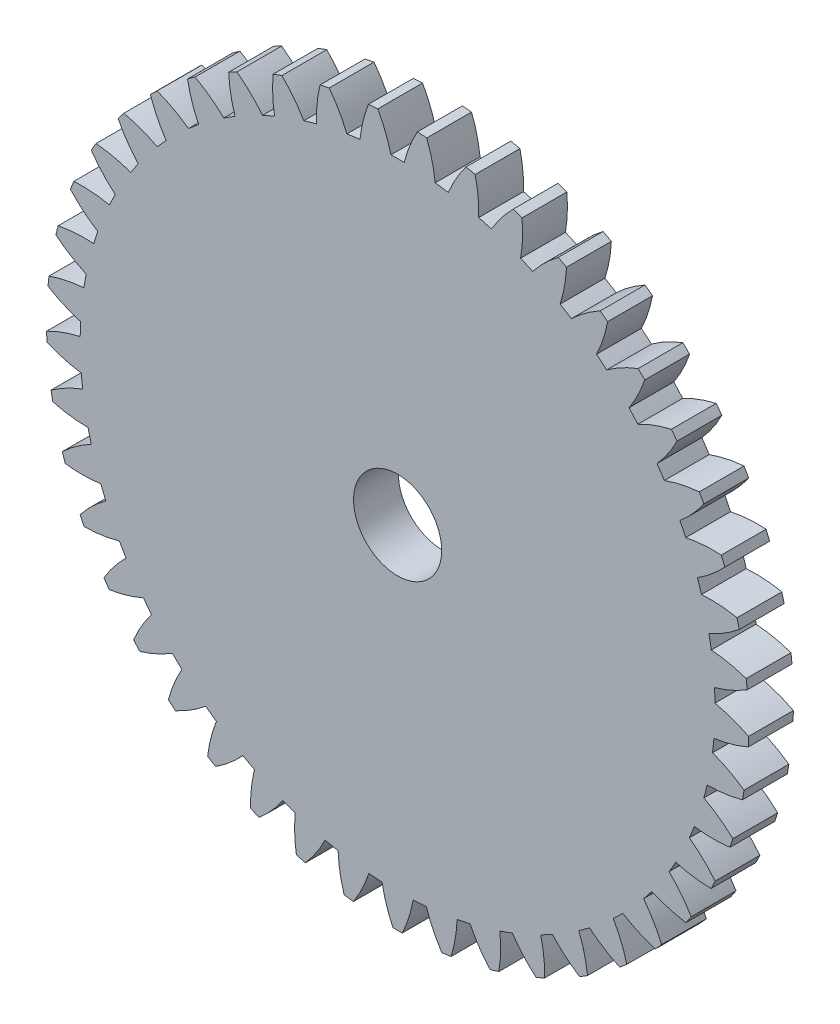
from build123d import *

# Parameters (mm, degrees)
BOSS_EXTRUDE1_DEPTH = 3
SKETCH2_R           = 2.95
CUT_EXTRUDE1_DEPTH  = 3


with BuildPart() as part:
    # Model → Boss-Extrude1 (new body)
    with BuildSketch(Plane.XY):
        with BuildLine():
            ThreePointArc((32.442634493, 93.418604181), (32.407825649, 93.107382285), (32.377167165, 92.795724168))
            ThreePointArc((32.377167165, 92.795724168), (33.438114337, 92.242398237), (34.563087863, 91.834705887))
            ThreePointArc((34.563087863, 91.834705887), (34.543034507, 91.392542803), (34.532195277, 90.950057955))
            ThreePointArc((34.532195277, 90.950057955), (33.381522949, 90.62183291), (32.284562125, 90.143862787))
            ThreePointArc((32.284562125, 90.143862787), (32.293405755, 89.830825225), (32.306420064, 89.517933307))
            ThreePointArc((32.306420064, 89.517933307), (33.434050257, 89.117647614), (34.604815427, 88.870488953))
            ThreePointArc((34.604815427, 88.870488953), (34.646494435, 88.429838082), (34.697342681, 87.990150937))
            ThreePointArc((34.697342681, 87.990150937), (33.603548714, 87.504977519), (32.583784022, 86.878991529))
            ThreePointArc((32.583784022, 86.878991529), (32.636107994, 86.570231223), (32.692541788, 86.262195589))
            ThreePointArc((32.692541788, 86.262195589), (33.864906962, 86.02274124), (35.058676163, 85.940926928))
            ThreePointArc((35.058676163, 85.940926928), (35.161276302, 85.510365038), (35.272822319, 85.082033606))
            ThreePointArc((35.272822319, 85.082033606), (34.25719617, 84.449355164), (33.334476169, 83.687537413))
            ThreePointArc((33.334476169, 83.687537413), (33.429262057, 83.38906403), (33.528016915, 83.091880244))
            ThreePointArc((33.528016915, 83.091880244), (34.722298316, 83.017917945), (35.915836189, 83.103040406))
            ThreePointArc((35.915836189, 83.103040406), (36.077360464, 82.690947894), (36.247433137, 82.282309159))
            ThreePointArc((36.247433137, 82.282309159), (35.329742812, 81.51444006), (34.522027198, 80.631618462))
            ThreePointArc((34.522027198, 80.631618462), (34.657430102, 80.349241448), (34.796583874, 80.068693855))
            ThreePointArc((34.796583874, 80.068693855), (35.989536173, 80.161663197), (37.15961186, 80.412065619))
            ThreePointArc((37.15961186, 80.412065619), (37.376916385, 80.026463398), (37.602205442, 79.645471048))
            ThreePointArc((37.602205442, 79.645471048), (36.80031274, 78.75735699), (36.123322778, 77.770714665))
            ThreePointArc((36.123322778, 77.770714665), (36.296707235, 77.509930166), (36.47355145, 77.251479304))
            ThreePointArc((36.47355145, 77.251479304), (37.641955188, 77.509570746), (38.765794498, 77.920379331))
            ThreePointArc((38.765794498, 77.920379331), (39.034649687, 77.568772709), (39.310770133, 77.222842327))
            ThreePointArc((39.310770133, 77.222842327), (38.640282982, 76.23176944), (38.107195512, 75.160510257))
            ThreePointArc((38.107195512, 75.160510257), (38.315186791, 74.926394149), (38.526279379, 74.69507047))
            ThreePointArc((38.526279379, 74.69507047), (39.647392905, 75.113260556), (40.703121583, 75.676479381))
            ThreePointArc((40.703121583, 75.676479381), (41.018294476, 75.365711981), (41.339871941, 75.061576708))
            ThreePointArc((41.339871941, 75.061576708), (40.813840613, 73.986835098), (40.435031575, 72.851809901))
            ThreePointArc((40.435031575, 72.851809901), (40.673581362, 72.648918985), (40.914813645, 72.449224943))
            ThreePointArc((40.914813645, 72.449224943), (41.966815761, 73.019374077), (42.933885249, 73.724040729))
            ThreePointArc((42.933885249, 73.724040729), (43.289241364, 73.460161285), (43.650016708, 73.203740769))
            ThreePointArc((43.650016708, 73.203740769), (43.278679803, 72.066249059), (43.061522286, 70.88954982))
            ThreePointArc((43.061522286, 70.88954982), (43.325987481, 70.721833138), (43.592664146, 70.55765555))
            ThreePointArc((43.592664146, 70.55765555), (44.555078827, 71.268666429), (45.414666218, 72.101065373))
            ThreePointArc((45.414666218, 72.101065373), (45.803288952, 71.889209997), (46.196240094, 71.685495172))
            ThreePointArc((46.196240094, 71.685495172), (45.986825263, 70.507393345), (45.935545989, 69.311923177))
            ThreePointArc((45.935545989, 69.311923177), (46.220779078, 69.182645144), (46.507709569, 69.057179539))
            ThreePointArc((46.507709569, 69.057179539), (47.361804507, 69.895213144), (48.09717891, 70.839142682))
            ThreePointArc((48.09717891, 70.839142682), (48.511504164, 70.683434899), (48.928982756, 70.536390841))
            ThreePointArc((48.928982756, 70.536390841), (48.88556602, 69.340609308), (49.001163084, 68.149636678))
            ThreePointArc((49.001163084, 68.149636678), (49.301612328, 68.061313543), (49.603211868, 67.977001967))
            ThreePointArc((49.603211868, 67.977001967), (50.332363078, 68.925746928), (50.929211268, 69.962834545))
            ThreePointArc((50.929211268, 69.962834545), (51.361174672, 69.86630503), (51.795054968, 69.778793785))
            ThreePointArc((51.795054968, 69.778793785), (51.918481385, 68.588607074), (52.19870482, 67.42531291))
            ThreePointArc((52.19870482, 67.42531291), (52.508522317, 67.379663782), (52.818920615, 67.338147264))
            ThreePointArc((52.818920615, 67.338147264), (53.408935997, 68.379137339), (53.855641001, 69.489197304))
            ThreePointArc((53.855641001, 69.489197304), (54.296834879, 69.453724894), (54.738671894, 69.427449769))
            ThreePointArc((54.738671894, 69.427449769), (55.026539108, 68.26602351), (55.465934684, 67.153050009))
            ThreePointArc((55.465934684, 67.153050009), (55.77909019, 67.150963398), (56.092245695, 67.153050009))
            ThreePointArc((56.092245695, 67.153050009), (56.531641271, 68.26602351), (56.819508486, 69.427449769))
            ThreePointArc((56.819508486, 69.427449769), (57.2613455, 69.453724894), (57.702539378, 69.489197304))
            ThreePointArc((57.702539378, 69.489197304), (58.149244383, 68.379137339), (58.739259765, 67.338147264))
            ThreePointArc((58.739259765, 67.338147264), (59.049658062, 67.379663782), (59.35947556, 67.42531291))
            ThreePointArc((59.35947556, 67.42531291), (59.639698995, 68.588607074), (59.763125412, 69.778793785))
            ThreePointArc((59.763125412, 69.778793785), (60.197005708, 69.86630503), (60.628969112, 69.962834545))
            ThreePointArc((60.628969112, 69.962834545), (61.225817302, 68.925746928), (61.954968511, 67.977001967))
            ThreePointArc((61.954968511, 67.977001967), (62.256568052, 68.061313543), (62.557017296, 68.149636678))
            ThreePointArc((62.557017296, 68.149636678), (62.672614359, 69.340609308), (62.629197623, 70.536390841))
            ThreePointArc((62.629197623, 70.536390841), (63.046676215, 70.683434899), (63.461001469, 70.839142682))
            ThreePointArc((63.461001469, 70.839142682), (64.196375873, 69.895213143), (65.050470811, 69.057179538))
            ThreePointArc((65.050470811, 69.057179538), (65.337401302, 69.182645143), (65.622634391, 69.311923176))
            ThreePointArc((65.622634391, 69.311923176), (65.571355117, 70.507393345), (65.361940286, 71.685495172))
            ThreePointArc((65.361940286, 71.685495172), (65.754891427, 71.889209997), (66.143514162, 72.101065373))
            ThreePointArc((66.143514162, 72.101065373), (67.003101553, 71.268666428), (67.965516234, 70.55765555))
            ThreePointArc((67.965516234, 70.55765555), (68.232192899, 70.721833138), (68.496658094, 70.88954982))
            ThreePointArc((68.496658094, 70.88954982), (68.279500577, 72.066249059), (67.908163672, 73.203740769))
            ThreePointArc((67.908163672, 73.203740769), (68.268939016, 73.460161284), (68.624295131, 73.724040729))
            ThreePointArc((68.624295131, 73.724040729), (69.591364619, 73.019374077), (70.643366735, 72.449224943))
            ThreePointArc((70.643366735, 72.449224943), (70.884599017, 72.648918985), (71.123148805, 72.8518099))
            ThreePointArc((71.123148805, 72.8518099), (70.744339767, 73.986835098), (70.218308439, 75.061576708))
            ThreePointArc((70.218308439, 75.061576708), (70.539885904, 75.36571198), (70.855058797, 75.676479381))
            ThreePointArc((70.855058797, 75.676479381), (71.910787474, 75.113260555), (73.031901001, 74.69507047))
            ThreePointArc((73.031901001, 74.69507047), (73.242993589, 74.926394148), (73.450984868, 75.160510257))
            ThreePointArc((73.450984868, 75.160510257), (72.917897397, 76.23176944), (72.247410247, 77.222842327))
            ThreePointArc((72.247410247, 77.222842327), (72.523530693, 77.568772709), (72.792385882, 77.920379331))
            ThreePointArc((72.792385882, 77.920379331), (73.916225192, 77.509570746), (75.084628929, 77.251479304))
            ThreePointArc((75.084628929, 77.251479304), (75.261473145, 77.509930166), (75.434857602, 77.770714665))
            ThreePointArc((75.434857602, 77.770714665), (74.75786764, 78.75735699), (73.955974938, 79.645471048))
            ThreePointArc((73.955974938, 79.645471048), (74.181263995, 80.026463398), (74.39856852, 80.412065619))
            ThreePointArc((74.39856852, 80.412065619), (75.568644207, 80.161663197), (76.761596506, 80.068693855))
            ThreePointArc((76.761596506, 80.068693855), (76.900750278, 80.349241448), (77.036153182, 80.631618462))
            ThreePointArc((77.036153182, 80.631618462), (76.228437568, 81.51444006), (75.310747243, 82.282309159))
            ThreePointArc((75.310747243, 82.282309159), (75.480819916, 82.690947894), (75.642344191, 83.103040406))
            ThreePointArc((75.642344191, 83.103040406), (76.835882063, 83.017917945), (78.030163465, 83.091880244))
            ThreePointArc((78.030163465, 83.091880244), (78.128918323, 83.38906403), (78.223704211, 83.687537413))
            ThreePointArc((78.223704211, 83.687537413), (77.30098421, 84.449355164), (76.28535806, 85.082033606))
            ThreePointArc((76.28535806, 85.082033606), (76.396904077, 85.510365038), (76.499504217, 85.940926928))
            ThreePointArc((76.499504217, 85.940926928), (77.693273418, 86.02274124), (78.865638592, 86.262195589))
            ThreePointArc((78.865638592, 86.262195589), (78.922072386, 86.570231223), (78.974396358, 86.878991529))
            ThreePointArc((78.974396358, 86.878991529), (77.954631666, 87.504977519), (76.860837699, 87.990150937))
            ThreePointArc((76.860837699, 87.990150937), (76.911685945, 88.429838082), (76.953364953, 88.870488953))
            ThreePointArc((76.953364953, 88.870488953), (78.124130123, 89.117647614), (79.251760315, 89.517933307))
            ThreePointArc((79.251760315, 89.517933307), (79.264774625, 89.830825225), (79.273618254, 90.143862787))
            ThreePointArc((79.273618254, 90.143862787), (78.176657431, 90.62183291), (77.025985103, 90.950057955))
            ThreePointArc((77.025985103, 90.950057955), (77.015145873, 91.392542803), (76.995092516, 91.834705887))
            ThreePointArc((76.995092516, 91.834705887), (78.120066043, 92.242398237), (79.181013214, 92.795724168))
            ThreePointArc((79.181013214, 92.795724168), (79.150354731, 93.107382285), (79.115545887, 93.418604181))
            ThreePointArc((79.115545887, 93.418604181), (77.962740026, 93.739255293), (76.777585865, 93.904143438))
            ThreePointArc((76.777585865, 93.904143438), (76.705270134, 94.340813525), (76.623874727, 94.77588262))
            ThreePointArc((76.623874727, 94.77588262), (77.68116028, 95.33617339), (78.654774301, 96.031769699))
            ThreePointArc((78.654774301, 96.031769699), (78.581039757, 96.336127944), (78.503255954, 96.639476596))
            ThreePointArc((78.503255954, 96.639476596), (77.317043112, 96.796567587), (76.120474794, 96.794909472))
            ThreePointArc((76.120474794, 96.794909472), (75.988090105, 97.217265511), (75.846936918, 97.636772493))
            ThreePointArc((75.846936918, 97.636772493), (76.815955636, 98.33875626), (77.683286217, 99.163083956))
            ThreePointArc((77.683286217, 99.163083956), (77.567910772, 99.454218343), (77.448665983, 99.743789414))
            ThreePointArc((77.448665983, 99.743789414), (76.252134442, 99.734262685), (75.06744181, 99.566090585))
            ThreePointArc((75.06744181, 99.566090585), (74.87756488, 99.965911896), (74.679401298, 100.361691538))
            ThreePointArc((74.679401298, 100.361691538), (75.541292335, 101.191704987), (76.285457873, 102.128719469))
            ThreePointArc((76.285457873, 102.128719469), (76.130687179, 102.400963398), (75.972302368, 102.671120715))
            ThreePointArc((75.972302368, 102.671120715), (74.788741254, 102.495161696), (73.638983002, 102.163748887))
            ThreePointArc((73.638983002, 102.163748887), (73.395309569, 102.533253404), (73.143992622, 102.897602305))
            ThreePointArc((73.143992622, 102.897602305), (73.881980249, 103.839490169), (74.488496408, 104.870953516))
            ThreePointArc((74.488496408, 104.870953516), (74.2973429, 105.119008068), (74.102900847, 105.364493328))
            ThreePointArc((74.102900847, 105.364493328), (72.955346831, 105.025526859), (71.862901696, 104.537323916))
            ThreePointArc((71.862901696, 104.537323916), (71.570174586, 104.869319652), (71.270595872, 105.195146176))
            ThreePointArc((71.270595872, 105.195146176), (71.870316, 106.230575679), (72.327377633, 107.33641163))
            ThreePointArc((72.327377633, 107.33641163), (72.103561896, 107.555448706), (71.876847195, 107.771483817))
            ThreePointArc((71.876847195, 107.771483817), (70.78763611, 107.276107495), (69.773767294, 106.640616732))
            ThreePointArc((69.773767294, 106.640616732), (69.437684108, 106.92864177), (69.095674586, 107.209604074))
            ThreePointArc((69.095674586, 107.209604074), (69.545454343, 108.318421758), (69.844165265, 109.477106474))
            ThreePointArc((69.844165265, 109.477106474), (69.592043619, 109.662862766), (69.337469014, 109.84524285))
            ThreePointArc((69.337469014, 109.84524285), (68.327801115, 109.203098612), (67.41224242, 108.432689135))
            ThreePointArc((67.41224242, 108.432689135), (67.039344636, 108.671137393), (66.661561131, 108.901766865))
            ThreePointArc((66.661561131, 108.901766865), (66.952646068, 110.062390856), (67.087192211, 111.251371857))
            ThreePointArc((67.087192211, 111.251371857), (66.811671915, 111.40023183), (66.534192411, 111.545407066))
            ThreePointArc((66.534192411, 111.545407066), (65.623719736, 110.76899352), (64.824291471, 109.878660472))
            ThreePointArc((64.824291471, 109.878660472), (64.421837119, 110.062890827), (64.015632758, 110.238698528))
            ThreePointArc((64.015632758, 110.238698528), (64.142357237, 111.428538598), (64.110119813, 112.624673722))
            ThreePointArc((64.110119813, 112.624673722), (63.816563558, 112.733739986), (63.521579977, 112.838884704))
            ThreePointArc((63.521579977, 112.838884704), (62.72802384, 111.943313856), (62.060285968, 110.950386557))
            ThreePointArc((62.060285968, 110.950386557), (61.636108364, 111.076813175), (61.209389454, 111.194377206))
            ThreePointArc((61.209389454, 111.194377206), (61.169286926, 112.390274474), (60.9708934, 113.570282311))
            ThreePointArc((60.9708934, 113.570282311), (60.665014924, 113.637432015), (60.358268787, 113.700499692))
            ThreePointArc((60.358268787, 113.700499692), (59.697074856, 112.703202809), (59.174024134, 111.62700746))
            ThreePointArc((59.174024134, 111.62700746), (58.736379412, 111.693169591), (58.29745155, 111.750201703))
            ThreePointArc((58.29745155, 111.750201703), (58.091302566, 112.928879387), (57.730614443, 114.069792427))
            ThreePointArc((57.730614443, 114.069792427), (57.418367323, 114.093718579), (57.105829094, 114.113481675))
            ThreePointArc((57.105829094, 114.113481675), (56.589866756, 113.033870007), (56.221683772, 111.895353526))
            ThreePointArc((56.221683772, 111.895353526), (55.77909019, 111.899963398), (55.336496608, 111.895353526))
            ThreePointArc((55.336496608, 111.895353526), (54.968313623, 113.033870007), (54.452351286, 114.113481674))
            ThreePointArc((54.452351286, 114.113481674), (54.139813057, 114.093718579), (53.827565937, 114.069792427))
            ThreePointArc((53.827565937, 114.069792427), (53.466877813, 112.928879387), (53.260728829, 111.750201703))
            ThreePointArc((53.260728829, 111.750201703), (52.821800968, 111.693169591), (52.384156246, 111.62700746))
            ThreePointArc((52.384156246, 111.62700746), (51.861105524, 112.703202809), (51.199911593, 113.700499692))
            ThreePointArc((51.199911593, 113.700499692), (50.893165456, 113.637432015), (50.58728698, 113.570282311))
            ThreePointArc((50.58728698, 113.570282311), (50.388893454, 112.390274474), (50.348790926, 111.194377206))
            ThreePointArc((50.348790926, 111.194377206), (49.922072016, 111.076813175), (49.497894412, 110.950386557))
            ThreePointArc((49.497894412, 110.950386557), (48.830156539, 111.943313856), (48.036600402, 112.838884704))
            ThreePointArc((48.036600402, 112.838884704), (47.741616822, 112.733739986), (47.448060567, 112.624673722))
            ThreePointArc((47.448060567, 112.624673722), (47.415823143, 111.428538598), (47.542547621, 110.238698528))
            ThreePointArc((47.542547621, 110.238698528), (47.136343261, 110.062890827), (46.733888908, 109.878660472))
            ThreePointArc((46.733888908, 109.878660472), (45.934460644, 110.76899352), (45.023987969, 111.545407066))
            ThreePointArc((45.023987969, 111.545407066), (44.746508464, 111.40023183), (44.470988169, 111.251371857))
            ThreePointArc((44.470988169, 111.251371857), (44.605534312, 110.062390856), (44.896619248, 108.901766866))
            ThreePointArc((44.896619248, 108.901766866), (44.518835744, 108.671137393), (44.145937959, 108.432689135))
            ThreePointArc((44.145937959, 108.432689135), (43.230379264, 109.203098612), (42.220711366, 109.84524285))
            ThreePointArc((42.220711366, 109.84524285), (41.966136761, 109.662862766), (41.714015114, 109.477106474))
            ThreePointArc((41.714015114, 109.477106474), (42.012726036, 108.318421758), (42.462505794, 107.209604074))
            ThreePointArc((42.462505794, 107.209604074), (42.120496272, 106.92864177), (41.784413086, 106.640616733))
            ThreePointArc((41.784413086, 106.640616733), (40.770544269, 107.276107495), (39.681333185, 107.771483817))
            ThreePointArc((39.681333185, 107.771483817), (39.454618484, 107.555448706), (39.230802747, 107.33641163))
            ThreePointArc((39.230802747, 107.33641163), (39.68786438, 106.230575679), (40.287584507, 105.195146176))
            ThreePointArc((40.287584507, 105.195146176), (39.988005793, 104.869319652), (39.695278684, 104.537323916))
            ThreePointArc((39.695278684, 104.537323916), (38.602833549, 105.025526859), (37.455279533, 105.364493328))
            ThreePointArc((37.455279533, 105.364493328), (37.26083748, 105.119008068), (37.069683971, 104.870953516))
            ThreePointArc((37.069683971, 104.870953516), (37.67620013, 103.839490169), (38.414187758, 102.897602305))
            ThreePointArc((38.414187758, 102.897602305), (38.162870811, 102.533253404), (37.919197377, 102.163748887))
            ThreePointArc((37.919197377, 102.163748887), (36.769439126, 102.495161696), (35.585878012, 102.671120715))
            ThreePointArc((35.585878012, 102.671120715), (35.427493201, 102.400963398), (35.272722506, 102.128719469))
            ThreePointArc((35.272722506, 102.128719469), (36.016888044, 101.191704987), (36.878779081, 100.361691538))
            ThreePointArc((36.878779081, 100.361691538), (36.6806155, 99.965911896), (36.490738569, 99.566090585))
            ThreePointArc((36.490738569, 99.566090585), (35.306045938, 99.734262686), (34.109514397, 99.743789414))
            ThreePointArc((34.109514397, 99.743789414), (33.990269607, 99.454218343), (33.874894162, 99.163083956))
            ThreePointArc((33.874894162, 99.163083956), (34.742224744, 98.33875626), (35.711243462, 97.636772493))
            ThreePointArc((35.711243462, 97.636772493), (35.570090275, 97.217265511), (35.437705585, 96.794909472))
            ThreePointArc((35.437705585, 96.794909472), (34.241137268, 96.796567587), (33.054924426, 96.639476596))
            ThreePointArc((33.054924426, 96.639476596), (32.977140622, 96.336127944), (32.903406079, 96.031769699))
            ThreePointArc((32.903406079, 96.031769699), (33.8770201, 95.33617339), (34.934305652, 94.77588262))
            ThreePointArc((34.934305652, 94.77588262), (34.852910246, 94.340813525), (34.780594515, 93.904143438))
            ThreePointArc((34.780594515, 93.904143438), (33.595440353, 93.739255293), (32.442634493, 93.418604181))
        make_face()
    extrude(amount=BOSS_EXTRUDE1_DEPTH)

    # Sketch2 → Cut-Extrude1 (cut)
    with BuildSketch(Plane.XY.offset(3)):
        with Locations((55.779090189, 90.650963398)):
            Circle(SKETCH2_R)
    extrude(amount=-CUT_EXTRUDE1_DEPTH, mode=Mode.SUBTRACT)


solid = part.part
